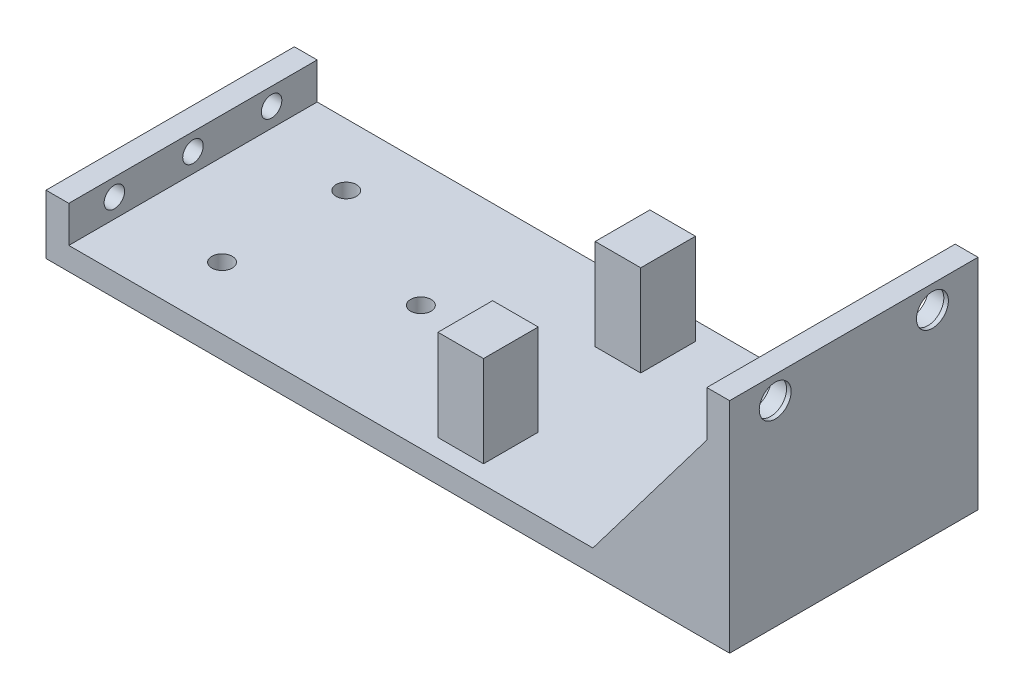
from build123d import *

# Parameters (mm, degrees)
SKETCH1_W                 = 150
SKETCH1_H                 = 54.5
BOSS_EXTRUDE1_DEPTH       = 5
SKETCH2_W                 = 5
SKETCH2_H                 = 54.5
BOSS_EXTRUDE2_DEPTH       = 8
F_8_CLEARANCE_HOLE1_D     = 4.4958
F_8_CLEARANCE_HOLE1_DEPTH = 17
F_8_CLEARANCE_HOLE1_TIP   = 1.350674586
SKETCH7_W                 = 5
SKETCH7_H                 = 54.5
BOSS_EXTRUDE3_DEPTH       = 43
SKETCH8_R                 = 4.25
CUT_EXTRUDE1_DEPTH        = 4
RIB1_REACH                = 120.085
SKETCH10_WALL_W           = 279.571445908
SKETCH10_WALL_H           = 10
RIB3_REACH                = 120.085
SKETCH12_WALL_W           = 279.571445908
SKETCH12_WALL_H           = 10
SKETCH13_W                = 8
SKETCH13_H                = 2
BOSS_EXTRUDE4_DEPTH       = 5
SKETCH14_R                = 2
CUT_EXTRUDE2_DEPTH        = 2
SKETCH15_R                = 3.5
CUT_EXTRUDE3_DEPTH        = 1
F_8_CLEARANCE_HOLE2_D     = 4.4958
F_8_CLEARANCE_HOLE2_DEPTH = 17
F_8_CLEARANCE_HOLE2_TIP   = 1.350674586
SKETCH16_W                = 10
SKETCH16_H                = 12
BOSS_EXTRUDE5_DEPTH       = 20
SKETCH18_W                = 7
SKETCH18_H                = 7
CUT_EXTRUDE4_DEPTH        = 8


with BuildPart() as part:
    # Sketch1 → Boss-Extrude1 (new body)
    with BuildSketch(Plane(origin=(0, 0, 0), x_dir=(1, 0, 0), z_dir=(0, 1, 0))):
        with Locations((-18.112463826, -1.689393939)):
            Rectangle(SKETCH1_W, SKETCH1_H)
    extrude(amount=BOSS_EXTRUDE1_DEPTH)

    # Sketch2 → Boss-Extrude2 (add)
    with BuildSketch(Plane(origin=(0, 5, 0), x_dir=(1, 0, 0), z_dir=(0, 1, 0))):
        with Locations((-90.612463826, -1.689393939)):
            Rectangle(SKETCH2_W, SKETCH2_H)
    extrude(amount=BOSS_EXTRUDE2_DEPTH)

    # #8 Clearance Hole1
    with Locations(Plane(origin=(-93.112463826, 9.2, -15.560606061), x_dir=(0, 0, -1), z_dir=(-1, 0, 0))):
        with Locations((0, 0), (-17.25, 0), (-34.5, 0)):
            Hole(F_8_CLEARANCE_HOLE1_D / 2, depth=F_8_CLEARANCE_HOLE1_DEPTH)
            with Locations((0, 0, -(F_8_CLEARANCE_HOLE1_DEPTH + F_8_CLEARANCE_HOLE1_TIP / 2))):  # 118° drill point
                Cone(0, F_8_CLEARANCE_HOLE1_D / 2, F_8_CLEARANCE_HOLE1_TIP, mode=Mode.SUBTRACT)

    # Sketch7 → Boss-Extrude3 (add)
    with BuildSketch(Plane(origin=(0, 5, 0), x_dir=(1, 0, 0), z_dir=(0, 1, 0))):
        with Locations((54.387536174, -1.689393939)):
            Rectangle(SKETCH7_W, SKETCH7_H)
    extrude(amount=BOSS_EXTRUDE3_DEPTH)

    # Sketch8 → Cut-Extrude1 (cut)
    with BuildSketch(Plane.ZY.offset(-51.887536174)):
        with Locations((-15.560606061, 43)):
            Circle(SKETCH8_R)
        with Locations((18.939393939, 43)):
            Circle(SKETCH8_R)
    extrude(amount=-CUT_EXTRUDE1_DEPTH, mode=Mode.SUBTRACT)

    # Sketch10 wall → Rib1 (add, up to next)
    with BuildSketch(Plane(origin=(39.387536174, 21.5, -25.560606061), x_dir=(-0.603857687995, -0.797092148154, 0), z_dir=(-0.797092148154, 0.603857687995, 0)), mode=Mode.PRIVATE) as rib1_sk1:
        with Locations((0, 5)):
            Rectangle(SKETCH10_WALL_W, SKETCH10_WALL_H)
    rib1_tool1 = extrude(rib1_sk1.sketch, amount=-RIB1_REACH, mode=Mode.PRIVATE) - part.part
    add(rib1_tool1.solids().sort_by_distance((39.387536174, 21.5, -25.560606061))[0])

    # Sketch12 wall → Rib3 (add, up to next)
    with BuildSketch(Plane(origin=(39.387536174, 21.5, 28.939393939), x_dir=(-0.603857687995, -0.797092148154, 0), z_dir=(0.797092148154, -0.603857687995, 0)), mode=Mode.PRIVATE) as rib3_sk1:
        with Locations((0, 5)):
            Rectangle(SKETCH12_WALL_W, SKETCH12_WALL_H)
    rib3_tool1 = extrude(rib3_sk1.sketch, amount=RIB3_REACH, mode=Mode.PRIVATE) - part.part
    add(rib3_tool1.solids().sort_by_distance((39.387536174, 21.5, 28.939393939))[0])

    # Sketch13 → Boss-Extrude4 (add)
    with BuildSketch(Plane.ZY.offset(-51.887536174)):
        with Locations((1.689393939, 37)):
            Rectangle(SKETCH13_W, SKETCH13_H)
    extrude(amount=BOSS_EXTRUDE4_DEPTH)

    # Sketch14 → Cut-Extrude2 (cut)
    with BuildSketch(Plane(origin=(0, 38, 0), x_dir=(1, 0, 0), z_dir=(0, 1, 0))):
        with Locations(Location((49.387536174, -1.689393939, 0), (0, 0, 270))):
            Circle(SKETCH14_R)
    extrude(amount=-CUT_EXTRUDE2_DEPTH, mode=Mode.SUBTRACT)

    # Sketch15 → Cut-Extrude3 (cut)
    with BuildSketch(Plane.ZY.offset(-55.887536174)):
        with Locations((-15.560606061, 43)):
            Circle(SKETCH15_R)
        with Locations((18.939393939, 43)):
            Circle(SKETCH15_R)
    extrude(amount=-CUT_EXTRUDE3_DEPTH, mode=Mode.SUBTRACT)

    # #8 Clearance Hole2
    with Locations(Plane(origin=(-38.112463826, 5, 1.689393939), x_dir=(0, 0, 1), z_dir=(0, 1, 0))):
        with Locations((0, 0), (13.625, -30), (-13.625, -30)):
            Hole(F_8_CLEARANCE_HOLE2_D / 2, depth=F_8_CLEARANCE_HOLE2_DEPTH)
            with Locations((0, 0, -(F_8_CLEARANCE_HOLE2_DEPTH + F_8_CLEARANCE_HOLE2_TIP / 2))):  # 118° drill point
                Cone(0, F_8_CLEARANCE_HOLE2_D / 2, F_8_CLEARANCE_HOLE2_TIP, mode=Mode.SUBTRACT)

    # Sketch16 → Boss-Extrude5 (add)
    with BuildSketch(Plane(origin=(0, 5, 0), x_dir=(1, 0, 0), z_dir=(0, 1, 0))):
        with Locations((-6.112463826, 15.560606061)):
            Rectangle(SKETCH16_W, SKETCH16_H)
        with Locations((-6.112463826, -18.939393939)):
            Rectangle(SKETCH16_W, SKETCH16_H)
    extrude(amount=BOSS_EXTRUDE5_DEPTH)

    # Sketch18 → Cut-Extrude4 (cut)
    with BuildSketch(Plane.ZY.offset(11.112463826)):
        with Locations((-15.560606061, 20)):
            Rectangle(SKETCH18_W, SKETCH18_H)
        with Locations((18.939393939, 20)):
            Rectangle(SKETCH18_W, SKETCH18_H)
    extrude(amount=-CUT_EXTRUDE4_DEPTH, mode=Mode.SUBTRACT)


solid = part.part
